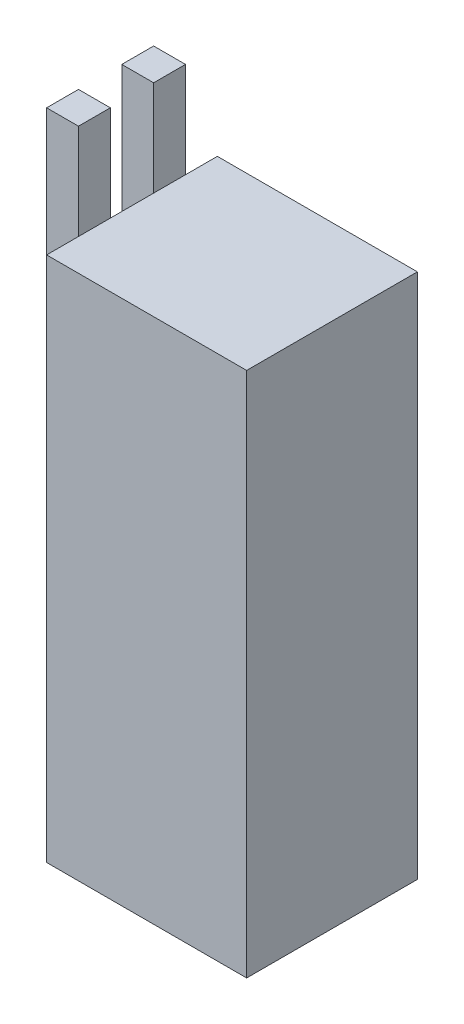
from build123d import *

# Parameters (mm, degrees)
SKETCH1_W           = 39.878
SKETCH1_H           = 34.036
BOSS_EXTRUDE1_DEPTH = 104.902
SKETCH3_W           = 6.35
SKETCH3_H           = 25.4
BOSS_EXTRUDE2_DEPTH = 6.35


with BuildPart() as part:
    # Sketch1 → Boss-Extrude1 (new body)
    with BuildSketch(Plane(origin=(0, 0, 0), x_dir=(1, 0, 0), z_dir=(0, 1, 0))):
        Rectangle(SKETCH1_W, SKETCH1_H)
    extrude(amount=BOSS_EXTRUDE1_DEPTH)

    # Sketch3 → Boss-Extrude2 (add)
    with BuildSketch(Plane(origin=(-19.939, 0, -2.921), x_dir=(0, 0, -1), z_dir=(1, 0, 0))):
        with Locations((4.572, 111.252)):
            Rectangle(SKETCH3_W, SKETCH3_H)
        with Locations((-10.414, 111.252)):
            Rectangle(SKETCH3_W, SKETCH3_H)
    extrude(amount=-BOSS_EXTRUDE2_DEPTH)


solid = part.part
